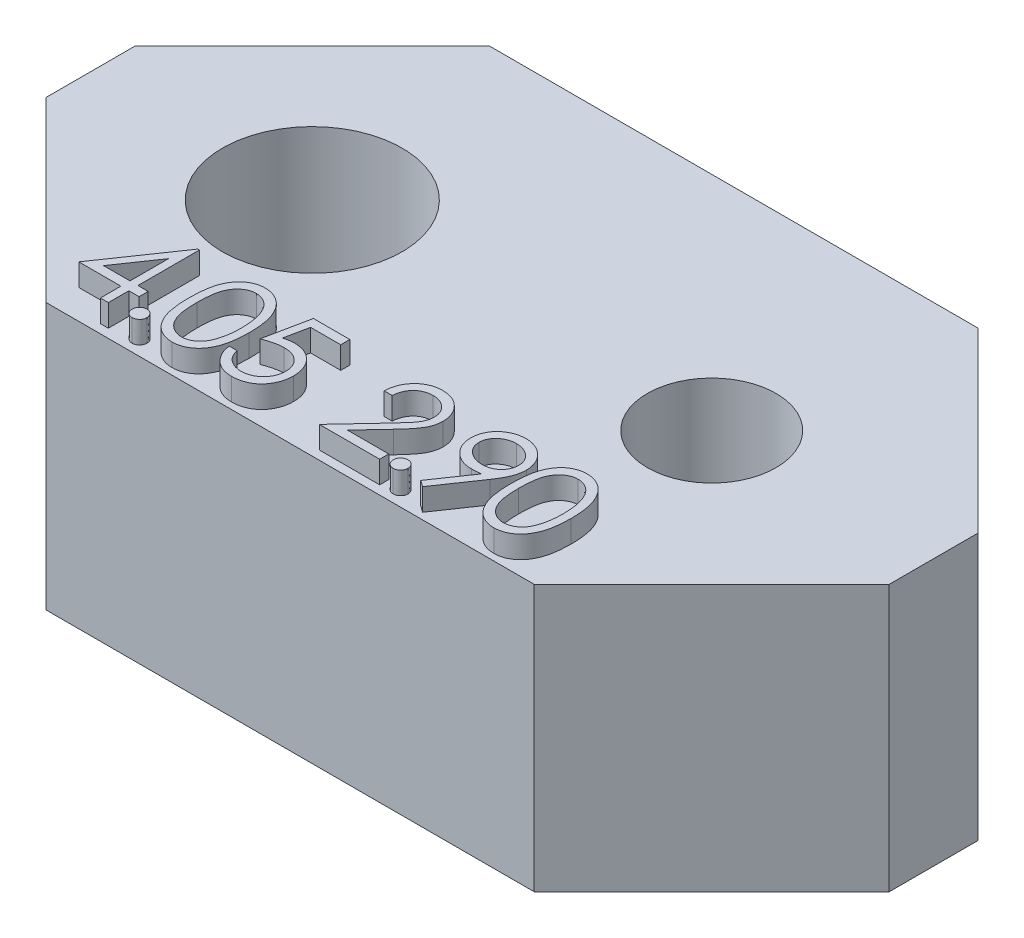
from build123d import *

# Parameters (mm, degrees)
SKETCH_1_R      = 2.025
SKETCH_1_R_2    = 1.45
EXTRUDE_1_DEPTH = 6
SKETCH_1_3_R    = 2.025
SKETCH_1_3_R_2  = 1.45
EXTRUDE_2_DEPTH = 2
EXTRUDE_3_DEPTH = 0.5


with BuildPart() as part:
    # Эскиз1 → Бобышка-Вытянуть1 (new body)
    with BuildSketch(Plane(origin=(0, 0, 0), x_dir=(1, 0, 0), z_dir=(0, 1, 0))):
        Polygon((9.5, 1), (5.5, 5), (-5.5, 5), (-9.5, 1), (-9.5, -1), (-5.5, -5), (5.5, -5), (9.5, -1), align=None)
        with Locations((-4.5, 0)):
            Circle(SKETCH_1_R, mode=Mode.SUBTRACT)
        with Locations((4.5, 0)):
            Circle(SKETCH_1_R_2, mode=Mode.SUBTRACT)
    extrude(amount=EXTRUDE_1_DEPTH)

    # Эскиз1<3> → Бобышка-Вытянуть2 (add)
    with BuildSketch(Plane(origin=(0, 0, 0), x_dir=(1, 0, 0), z_dir=(0, 1, 0))):
        with Locations((-4.5, 0)):
            Circle(SKETCH_1_3_R)
        with Locations((4.5, 0)):
            Circle(SKETCH_1_3_R_2)
    extrude(amount=EXTRUDE_2_DEPTH)

    # Эскиз3 → Бобышка-Вытянуть3 (add)
    # profile 1 of 8: a face of its own
    with BuildSketch(Plane(origin=(0, 6, 0), x_dir=(1, 0, 0), z_dir=(0, 1, 0))):
        Polygon((-4.331330128, -2.748717949), (-4.294871795, -2.748717949), (-4.294871795, -4.133333333), (-4.064102564, -4.133333333), (-4.064102564, -4.338461538), (-4.294871795, -4.338461538), (-4.294871795, -4.8), (-4.474358974, -4.8), (-4.474358974, -4.338461538), (-5.423076923, -4.338461538), align=None)
        Polygon((-4.474358974, -4.133333333), (-4.474358974, -3.26474359), (-5.070512821, -4.133333333), align=None, mode=Mode.SUBTRACT)
    # profile 2 of 8: a face of its own
    with BuildSketch(Plane(origin=(0, 6, 0), x_dir=(1, 0, 0), z_dir=(0, 1, 0))):
        with BuildLine():
            add(Edge.make_bspline(
                [(-3.733333333, -4.492307692), (-3.722196069, -4.492969502), (-3.700362765, -4.494266902), (-3.668797549, -4.503167858), (-3.640229172, -4.518972807), (-3.614782175, -4.540037252), (-3.593807045, -4.565577631), (-3.577438844, -4.59391815), (-3.568615424, -4.625747632), (-3.567327474, -4.647707446), (-3.566666667, -4.658974359)],
                knots=[0, 0, 0, 0, 1.020151414, 1.999887582, 2.974338812, 3.990962822, 5.007586832, 5.987933904, 6.967670073, 8, 8, 8, 8], degree=3))
            add(Edge.make_bspline(
                [(-3.566666667, -4.658974359), (-3.567349867, -4.669970547), (-3.568697128, -4.69165487), (-3.577418619, -4.723244277), (-3.59393179, -4.751602508), (-3.6146375, -4.777489444), (-3.640235462, -4.798598513), (-3.668865089, -4.814268996), (-3.700288665, -4.82380727), (-3.722183707, -4.825022297), (-3.733333333, -4.825641026)],
                knots=[0, 0, 0, 0, 1.009421747, 1.99056486, 2.972319754, 3.999869655, 5.017953583, 5.993804169, 6.978383603, 8, 8, 8, 8], degree=3))
            add(Edge.make_bspline(
                [(-3.733333333, -4.825641026), (-3.744490994, -4.825044684), (-3.766273669, -4.82388047), (-3.797579952, -4.814073152), (-3.826383934, -4.798745461), (-3.851976912, -4.777450084), (-3.872856039, -4.751735716), (-3.888641972, -4.723048975), (-3.898122057, -4.691745297), (-3.899368841, -4.669988358), (-3.9, -4.658974359)],
                knots=[0, 0, 0, 0, 1.022052826, 1.995314843, 2.982371812, 4.00089066, 5.028879526, 6.005146991, 6.990147033, 8, 8, 8, 8], degree=3))
            add(Edge.make_bspline(
                [(-3.9, -4.658974359), (-3.899393086, -4.647688999), (-3.898208161, -4.625655719), (-3.88862207, -4.594113372), (-3.87297852, -4.565445692), (-3.85183258, -4.540076218), (-3.826390125, -4.518826331), (-3.797649437, -4.503360735), (-3.766198271, -4.494194785), (-3.744478306, -4.492947633), (-3.733333333, -4.492307692)],
                knots=[0, 0, 0, 0, 1.032775665, 2.016367738, 2.991239715, 4.008302682, 5.025365648, 6.011011707, 6.979408107, 8, 8, 8, 8], degree=3))
        make_face()
    # profile 3 of 8: a face of its own
    with BuildSketch(Plane(origin=(0, 6, 0), x_dir=(1, 0, 0), z_dir=(0, 1, 0))):
        with BuildLine():
            add(Edge.make_bspline(
                [(-3.479487179, -3.800801282), (-3.479299741, -3.768745632), (-3.478935638, -3.706477069), (-3.474885111, -3.615742988), (-3.468156344, -3.530622823), (-3.458934988, -3.4511125), (-3.447713285, -3.377191491), (-3.432733007, -3.309057344), (-3.41569712, -3.246394712), (-3.395952865, -3.188999256), (-3.373674129, -3.136097711), (-3.34942598, -3.086711882), (-3.322246097, -3.040916492), (-3.293687861, -2.997980612), (-3.262595249, -2.958607072), (-3.229853083, -2.922239836), (-3.19418344, -2.889719407), (-3.156798863, -2.860092949), (-3.117360884, -2.834121822), (-3.076993646, -2.811245972), (-3.0354193, -2.79170319), (-2.992524338, -2.776337227), (-2.948694305, -2.763645314), (-2.903775981, -2.754965916), (-2.857695202, -2.749504825), (-2.826591525, -2.748982729), (-2.810817308, -2.748717949)],
                knots=[0, 0, 0, 0, 1.646270934, 3.197905019, 4.663502075, 6.030701355, 7.308322542, 8.50163776, 9.611534131, 10.641858119, 11.616356847, 12.558055219, 13.465016945, 14.349605745, 15.204443733, 16.039544428, 16.859896111, 17.680448484, 18.487036065, 19.28249412, 20.06191084, 20.843045899, 21.620316918, 22.403196591, 23.190181807, 24, 24, 24, 24], degree=3))
            add(Edge.make_bspline(
                [(-2.810817308, -2.748717949), (-2.79491132, -2.7489967), (-2.763279315, -2.749551049), (-2.716513386, -2.754879016), (-2.670827854, -2.763719658), (-2.626417489, -2.776245929), (-2.582917497, -2.791786316), (-2.540668121, -2.811264669), (-2.499406931, -2.833938307), (-2.459789624, -2.860580523), (-2.421381272, -2.890284681), (-2.385125294, -2.923863349), (-2.351018387, -2.960977474), (-2.318632499, -3.001229968), (-2.288886443, -3.045392873), (-2.260558767, -3.092698079), (-2.235203318, -3.143972859), (-2.210783504, -3.198361697), (-2.189705226, -3.257369502), (-2.170695943, -3.320663651), (-2.155336532, -3.388991758), (-2.142542662, -3.461995327), (-2.132631293, -3.53994246), (-2.125412641, -3.622666069), (-2.121599449, -3.710220578), (-2.120881334, -3.770082206), (-2.120512821, -3.800801282)],
                knots=[0, 0, 0, 0, 0.810914788, 1.612654377, 2.396697861, 3.181598691, 3.963628158, 4.749916497, 5.551656086, 6.361998678, 7.18212741, 8.025565596, 8.878627764, 9.750805457, 10.657531673, 11.591944965, 12.560506719, 13.57287815, 14.630710178, 15.753379473, 16.941251878, 18.199788006, 19.531962791, 20.947069417, 22.433333509, 24, 24, 24, 24], degree=3))
            add(Edge.make_bspline(
                [(-2.120512821, -3.800801282), (-2.120885155, -3.831386372), (-2.121610632, -3.890980173), (-2.125369893, -3.978140731), (-2.132774825, -4.060425327), (-2.142037676, -4.138031305), (-2.154866797, -4.210635659), (-2.170641178, -4.27848963), (-2.188155648, -4.341886242), (-2.209775531, -4.400306134), (-2.233438794, -4.454564262), (-2.25918462, -4.505231204), (-2.286767378, -4.552754799), (-2.316818089, -4.596754655), (-2.348848611, -4.637542459), (-2.38354449, -4.674398243), (-2.419927682, -4.708210056), (-2.458449062, -4.7382967), (-2.498684235, -4.764630874), (-2.539803707, -4.788181646), (-2.582537069, -4.807171757), (-2.625915899, -4.823477495), (-2.67056068, -4.835934896), (-2.71641576, -4.844548528), (-2.763247895, -4.850589584), (-2.794905932, -4.85105043), (-2.810817308, -4.851282051)],
                knots=[0, 0, 0, 0, 1.561518951, 3.042555995, 4.452378317, 5.7783523, 7.031515105, 8.214008947, 9.334062868, 10.386615937, 11.391082383, 12.354592575, 13.286541444, 14.194233754, 15.072674879, 15.931287219, 16.775624067, 17.606195743, 18.42308326, 19.229000347, 20.022332153, 20.807536673, 21.593273796, 22.3848459, 23.188221202, 24, 24, 24, 24], degree=3))
            add(Edge.make_bspline(
                [(-2.810817308, -4.851282051), (-2.826591087, -4.851015562), (-2.857693901, -4.850490098), (-2.903781002, -4.84505368), (-2.948513826, -4.836313393), (-2.992113114, -4.824075333), (-3.034802552, -4.809095427), (-3.07600043, -4.789579036), (-3.11616482, -4.767102426), (-3.155188567, -4.741505042), (-3.192338373, -4.712178366), (-3.22782329, -4.679741629), (-3.260751873, -4.643385394), (-3.291399927, -4.603683724), (-3.320527978, -4.561001871), (-3.347321905, -4.514757087), (-3.37210525, -4.465132738), (-3.394758674, -4.411808217), (-3.414843624, -4.354005401), (-3.432585172, -4.291063014), (-3.446593262, -4.222425507), (-3.458583522, -4.148644155), (-3.468254598, -4.069401909), (-3.47485707, -3.98465575), (-3.478937821, -3.894458488), (-3.479300718, -3.832590045), (-3.479487179, -3.800801282)],
                knots=[0, 0, 0, 0, 0.810891512, 1.598919785, 2.382837074, 3.152667961, 3.926044502, 4.706494248, 5.493654104, 6.291793342, 7.103789334, 7.925228297, 8.761435821, 9.622817696, 10.50288917, 11.416980706, 12.369136599, 13.353924996, 14.394355917, 15.514179734, 16.714354668, 17.994756427, 19.357759367, 20.818452758, 22.365282078, 24, 24, 24, 24], degree=3))
        make_face()
        with BuildLine():
            add(Edge.make_bspline(
                [(-3.3, -3.8), (-3.299931745, -3.826713542), (-3.299799274, -3.878559282), (-3.296338588, -3.953898288), (-3.29162417, -4.024167048), (-3.285543428, -4.089454783), (-3.276513172, -4.149540504), (-3.266395008, -4.204837466), (-3.254081814, -4.25505303), (-3.239513232, -4.300531779), (-3.222919462, -4.342045532), (-3.204801826, -4.380674798), (-3.185338556, -4.416875905), (-3.163556184, -4.450323681), (-3.139833291, -4.481127203), (-3.114705714, -4.509831679), (-3.087235666, -4.535429954), (-3.049233527, -4.566131014), (-2.999064113, -4.597856233), (-2.935852425, -4.62548257), (-2.870899024, -4.642843974), (-2.826812596, -4.645051835), (-2.804807692, -4.646153846)],
                knots=[0, 0, 0, 0, 1.459021318, 2.831673884, 4.118529203, 5.306027144, 6.411944654, 7.436330062, 8.375795394, 9.233974572, 10.042671642, 10.816086306, 11.563610507, 12.285937304, 12.993564865, 13.685989202, 14.367179055, 15.041617293, 16.353048772, 17.594441528, 18.799311195, 20, 20, 20, 20], degree=3))
            add(Edge.make_bspline(
                [(-2.804807692, -4.646153846), (-2.782660451, -4.645240829), (-2.738411695, -4.643416678), (-2.673763812, -4.6258174), (-2.611003658, -4.599263377), (-2.561819692, -4.567864803), (-2.524401096, -4.5379629), (-2.497591387, -4.512468816), (-2.472984502, -4.483922606), (-2.449646174, -4.453123008), (-2.428240988, -4.419481588), (-2.408776338, -4.383160117), (-2.391014425, -4.344057729), (-2.38089497, -4.316760736), (-2.375721154, -4.302804487)],
                knots=[0, 0, 0, 0, 1.353760809, 2.704726607, 4.075137775, 5.516104923, 6.260822281, 7.007110065, 7.778089737, 8.566572457, 9.372053459, 10.217411131, 11.088608312, 12, 12, 12, 12], degree=3))
            add(Edge.make_bspline(
                [(-2.375721154, -4.302804487), (-2.369691572, -4.284958922), (-2.357448936, -4.248724771), (-2.341670779, -4.19251697), (-2.329244837, -4.133543962), (-2.318065771, -4.072158181), (-2.310435453, -4.007906923), (-2.304293845, -3.940988989), (-2.30067631, -3.871353925), (-2.300227881, -3.824042502), (-2.3, -3.8)],
                knots=[0, 0, 0, 0, 0.884706709, 1.796334032, 2.740027952, 3.714592787, 4.726048262, 5.777819803, 6.87074269, 8, 8, 8, 8], degree=3))
            add(Edge.make_bspline(
                [(-2.3, -3.8), (-2.300314394, -3.775961387), (-2.300929415, -3.728936722), (-2.303280266, -3.66006919), (-2.30935088, -3.594659041), (-2.316093233, -3.532424485), (-2.326034502, -3.473710026), (-2.336753249, -3.418024137), (-2.351153942, -3.366056695), (-2.36653667, -3.316994077), (-2.384142611, -3.271393703), (-2.40352303, -3.229042967), (-2.424221178, -3.18973741), (-2.446702458, -3.153584872), (-2.470699992, -3.120423419), (-2.496847163, -3.090917937), (-2.524106804, -3.064153955), (-2.562288053, -3.033603915), (-2.612273362, -3.002454375), (-2.674470874, -2.973788227), (-2.739196957, -2.957326345), (-2.782953216, -2.955005381), (-2.804807692, -2.953846154)],
                knots=[0, 0, 0, 0, 1.31362396, 2.569729283, 3.763502607, 4.902122613, 5.988968491, 7.01645872, 7.998833611, 8.933434873, 9.825090667, 10.667526885, 11.477055099, 12.250526234, 12.991942729, 13.710640831, 14.402115721, 15.076753259, 16.378508321, 17.609869233, 18.806226677, 20, 20, 20, 20], degree=3))
            add(Edge.make_bspline(
                [(-2.804807692, -2.953846154), (-2.826928031, -2.955006981), (-2.871209005, -2.957330749), (-2.936607837, -2.973726893), (-2.999296037, -3.002305731), (-3.049149166, -3.033707087), (-3.087357044, -3.063614693), (-3.11426144, -3.08954981), (-3.139487824, -3.117919098), (-3.16272651, -3.149005907), (-3.184491815, -3.182414688), (-3.204480965, -3.218408268), (-3.222490867, -3.257169047), (-3.239110602, -3.298664153), (-3.253723624, -3.344138979), (-3.265777317, -3.394292689), (-3.276912776, -3.44941377), (-3.284795787, -3.509824918), (-3.291803648, -3.575129005), (-3.296307275, -3.645573187), (-3.299810851, -3.721038548), (-3.299935687, -3.773152352), (-3.3, -3.8)],
                knots=[0, 0, 0, 0, 1.207732386, 2.417664972, 3.655092373, 4.956220595, 5.625982001, 6.301752483, 6.994047911, 7.697131622, 8.419323945, 9.170223765, 9.943494443, 10.752040957, 11.610060368, 12.549350801, 13.567764191, 14.679664412, 15.874934091, 17.154273443, 18.533957287, 20, 20, 20, 20], degree=3))
        make_face(mode=Mode.SUBTRACT)
    # profile 4 of 8: a face of its own
    with BuildSketch(Plane(origin=(0, 6, 0), x_dir=(1, 0, 0), z_dir=(0, 1, 0))):
        with BuildLine():
            Line((-0.853846154, -2.8), (-0.853846154, -3.005128205))
            Line((-0.853846154, -3.005128205), (-1.534134615, -3.005128205))
            Line((-1.534134615, -3.005128205), (-1.641907051, -3.531169872))
            add(Edge.make_bspline(
                [(-1.641907051, -3.531169872), (-1.620732266, -3.525324002), (-1.579709468, -3.513998554), (-1.519160976, -3.501423828), (-1.461679717, -3.493843575), (-1.424379506, -3.49280854), (-1.406330128, -3.492307692)],
                knots=[0, 0, 0, 0, 1.100273476, 2.13160584, 3.095893838, 4, 4, 4, 4], degree=3))
            add(Edge.make_bspline(
                [(-1.406330128, -3.492307692), (-1.383996563, -3.492791084), (-1.340083193, -3.493741553), (-1.275832366, -3.502868324), (-1.214499284, -3.51723399), (-1.156212215, -3.537302859), (-1.100863329, -3.562965564), (-1.048961866, -3.595022673), (-0.999728772, -3.632470291), (-0.95404729, -3.675524583), (-0.912604828, -3.722908364), (-0.87616712, -3.773855719), (-0.845217068, -3.827871526), (-0.820325208, -3.885471874), (-0.800448446, -3.946019962), (-0.787218735, -4.010152866), (-0.778409187, -4.077266077), (-0.777424966, -4.123154403), (-0.776923077, -4.146554487)],
                knots=[0, 0, 0, 0, 1.052922333, 2.070308379, 3.05430497, 4.020497103, 4.973039431, 5.925935799, 6.892292201, 7.88610001, 8.88166317, 9.857072816, 10.836096531, 11.812156883, 12.81219415, 13.836441305, 14.89672472, 16, 16, 16, 16], degree=3))
            add(Edge.make_bspline(
                [(-0.776923077, -4.146554487), (-0.77730312, -4.162852899), (-0.77805807, -4.195229463), (-0.781897263, -4.243311864), (-0.789289101, -4.29037634), (-0.799213514, -4.336429135), (-0.812094896, -4.381383062), (-0.827688641, -4.425366792), (-0.846772086, -4.468106567), (-0.8677043, -4.510006793), (-0.891273716, -4.550120226), (-0.917432863, -4.587633932), (-0.945070287, -4.623110665), (-0.974808221, -4.656169941), (-1.006923076, -4.686594522), (-1.041025914, -4.714564969), (-1.07684461, -4.740554301), (-1.11493332, -4.763507555), (-1.15444331, -4.784629244), (-1.195945149, -4.80195698), (-1.238494121, -4.81744871), (-1.282702621, -4.829797012), (-1.328470514, -4.839472757), (-1.375873243, -4.846044529), (-1.424662197, -4.850831064), (-1.457733633, -4.851130697), (-1.474439103, -4.851282051)],
                knots=[0, 0, 0, 0, 1.056347294, 2.098418968, 3.122841568, 4.141288669, 5.149314143, 6.15115421, 7.162517403, 8.180376062, 9.185164535, 10.17417709, 11.141909838, 12.097768115, 13.052685741, 14.0056014, 14.954263652, 15.917497458, 16.885230207, 17.854509472, 18.828990115, 19.81800267, 20.826176721, 21.857883937, 22.917946725, 24, 24, 24, 24], degree=3))
            add(Edge.make_bspline(
                [(-1.474439103, -4.851282051), (-1.494367206, -4.850887287), (-1.533573395, -4.850110634), (-1.591013719, -4.841985785), (-1.646279208, -4.830349262), (-1.69892498, -4.812842822), (-1.749422845, -4.790907225), (-1.797092969, -4.763183698), (-1.843153413, -4.731767068), (-1.885731719, -4.69469258), (-1.925249499, -4.654169333), (-1.960624647, -4.610193538), (-1.992129548, -4.563491), (-2.019259689, -4.513834912), (-2.042401415, -4.461355751), (-2.060581408, -4.405856894), (-2.075254754, -4.34762832), (-2.081462423, -4.3075406), (-2.084615385, -4.287179487)],
                knots=[0, 0, 0, 0, 1.0467383, 2.05933395, 3.04377827, 4.011590433, 4.970194871, 5.932262533, 6.905835911, 7.896367577, 8.894135286, 9.877477877, 10.858688626, 11.851381753, 12.8477658, 13.868841284, 14.917554742, 16, 16, 16, 16], degree=3))
            Line((-2.084615385, -4.287179487), (-1.905128205, -4.287179487))
            add(Edge.make_bspline(
                [(-1.905128205, -4.287179487), (-1.900711887, -4.306251746), (-1.892223477, -4.342909686), (-1.873591621, -4.394413309), (-1.850811121, -4.440310009), (-1.823722921, -4.481206913), (-1.791408618, -4.516869197), (-1.754534659, -4.548650376), (-1.713193103, -4.577321878), (-1.667254114, -4.601220602), (-1.618789498, -4.621602747), (-1.568065378, -4.635175144), (-1.516462894, -4.644718511), (-1.481560968, -4.645673803), (-1.464022436, -4.646153846)],
                knots=[0, 0, 0, 0, 1.136247022, 2.183929868, 3.172523383, 4.106158343, 5.02341133, 5.958108904, 6.928429099, 7.938127109, 8.96079061, 9.975095812, 10.982467395, 12, 12, 12, 12], degree=3))
            add(Edge.make_bspline(
                [(-1.464022436, -4.646153846), (-1.446903325, -4.64568483), (-1.413195655, -4.644761334), (-1.363589148, -4.637653327), (-1.315696077, -4.626706143), (-1.269989016, -4.610323369), (-1.225668137, -4.590412102), (-1.183854553, -4.56486063), (-1.143338624, -4.535454905), (-1.10537969, -4.501765402), (-1.070614291, -4.464639862), (-1.039896507, -4.424938494), (-1.014309699, -4.382586011), (-0.992747352, -4.338315638), (-0.976374038, -4.291642176), (-0.964693477, -4.242784362), (-0.957834586, -4.191621516), (-0.956891055, -4.156724768), (-0.956410256, -4.138942308)],
                knots=[0, 0, 0, 0, 1.027316725, 2.022795036, 3.002884548, 3.971462791, 4.93288096, 5.914575861, 6.907176829, 7.935150275, 8.956128384, 9.956726525, 10.942570165, 11.921478529, 12.907843606, 13.90538589, 14.932640048, 16, 16, 16, 16], degree=3))
            add(Edge.make_bspline(
                [(-0.956410256, -4.138942308), (-0.95678653, -4.122899021), (-0.957523033, -4.09149657), (-0.963540502, -4.045554166), (-0.974007343, -4.002083857), (-0.988535275, -3.960875723), (-1.006980708, -3.921890899), (-1.029521458, -3.88508915), (-1.056580542, -3.850955531), (-1.087490193, -3.819474072), (-1.12135193, -3.790419858), (-1.158748355, -3.765651808), (-1.198896884, -3.744815284), (-1.241313798, -3.72683357), (-1.287008026, -3.713918859), (-1.335074673, -3.704222924), (-1.386032792, -3.698614146), (-1.420873185, -3.697835924), (-1.438782051, -3.697435897)],
                knots=[0, 0, 0, 0, 1.045622112, 2.046656509, 3.013763289, 3.955457236, 4.890082067, 5.820317437, 6.762574623, 7.722996705, 8.69280354, 9.665887285, 10.63943826, 11.638615906, 12.663482002, 13.728887084, 14.832589034, 16, 16, 16, 16], degree=3))
            add(Edge.make_bspline(
                [(-1.438782051, -3.697435897), (-1.454284296, -3.697767664), (-1.486292499, -3.698452677), (-1.535391257, -3.70349639), (-1.586986528, -3.711633129), (-1.640880525, -3.722825271), (-1.697235101, -3.7374716), (-1.75593133, -3.755022744), (-1.817092625, -3.776006743), (-1.858302754, -3.791853722), (-1.879487179, -3.8)],
                knots=[0, 0, 0, 0, 0.817624296, 1.688186739, 2.600797293, 3.572016777, 4.590301741, 5.671205678, 6.80286297, 8, 8, 8, 8], degree=3))
            Line((-1.879487179, -3.8), (-1.674358974, -2.8))
            Line((-1.674358974, -2.8), (-0.853846154, -2.8))
        make_face()
    # profile 5 of 8: a face of its own
    with BuildSketch(Plane(origin=(0, 6, 0), x_dir=(1, 0, 0), z_dir=(0, 1, 0))):
        with BuildLine():
            Line((0.715384615, -3.415384615), (0.535897436, -3.415384615))
            add(Edge.make_bspline(
                [(0.535897436, -3.415384615), (0.537067238, -3.39157268), (0.539364697, -3.344806671), (0.550123719, -3.276621582), (0.565518506, -3.211447411), (0.587285052, -3.14980746), (0.61431721, -3.091156713), (0.646734369, -3.035728133), (0.685130855, -2.983733168), (0.72867756, -2.935653829), (0.775973925, -2.891546646), (0.827005891, -2.853457935), (0.88063162, -2.821276409), (0.93668842, -2.794372842), (0.995808742, -2.774178644), (1.057456089, -2.75919485), (1.12190131, -2.750179796), (1.165809894, -2.749210775), (1.188141026, -2.748717949)],
                knots=[0, 0, 0, 0, 1.10065271, 2.161652631, 3.183658789, 4.190468796, 5.17591951, 6.163126047, 7.15150782, 8.156236427, 9.156009102, 10.134482811, 11.092018607, 12.041330605, 13.001268258, 13.972401359, 14.968799086, 16, 16, 16, 16], degree=3))
            add(Edge.make_bspline(
                [(1.188141026, -2.748717949), (1.210071354, -2.749231352), (1.253163665, -2.750240172), (1.316056245, -2.758903618), (1.375928984, -2.772472527), (1.432664851, -2.791509908), (1.485811173, -2.817101009), (1.535767199, -2.84784246), (1.583127662, -2.883396649), (1.62576011, -2.925255971), (1.664907584, -2.969943048), (1.698680301, -3.017650422), (1.727602109, -3.066924299), (1.751709354, -3.118140414), (1.76945572, -3.171781002), (1.782928981, -3.227065118), (1.790544646, -3.28456501), (1.79171346, -3.323483042), (1.792307692, -3.343269231)],
                knots=[0, 0, 0, 0, 1.111607364, 2.184268762, 3.212621178, 4.221274766, 5.211760367, 6.196651075, 7.1921475, 8.207485113, 9.220403448, 10.201281604, 11.166441695, 12.114753415, 13.065576456, 14.026450734, 14.996634279, 16, 16, 16, 16], degree=3))
            add(Edge.make_bspline(
                [(1.792307692, -3.343269231), (1.791340114, -3.371125136), (1.789421936, -3.426348115), (1.77301372, -3.507499466), (1.747387143, -3.586124277), (1.71653151, -3.649402735), (1.685404399, -3.700393303), (1.657354395, -3.74237542), (1.62451736, -3.787578545), (1.586415361, -3.835851309), (1.543836577, -3.887571826), (1.496395341, -3.942708852), (1.443753351, -4.00069272), (1.406805637, -4.040295921), (1.387660256, -4.060817308)],
                knots=[0, 0, 0, 0, 1.184426356, 2.348067706, 3.509069118, 4.696110526, 5.333549288, 6.050745305, 6.844228056, 7.710549037, 8.667450064, 9.695053472, 10.805634456, 12, 12, 12, 12], degree=3))
            Line((1.387660256, -4.060817308), (0.887259615, -4.594871795))
            Line((0.887259615, -4.594871795), (1.817948718, -4.594871795))
            Line((1.817948718, -4.594871795), (1.817948718, -4.8))
            Line((1.817948718, -4.8), (0.458974359, -4.8))
            Line((0.458974359, -4.8), (1.234615385, -3.972275641))
            add(Edge.make_bspline(
                [(1.234615385, -3.972275641), (1.253499891, -3.952562323), (1.289773164, -3.914697074), (1.341077494, -3.859415382), (1.387156916, -3.80812993), (1.428309711, -3.760937617), (1.463643143, -3.717148149), (1.494998704, -3.678179747), (1.520121899, -3.642320061), (1.547387839, -3.600753996), (1.573795829, -3.550004101), (1.596488604, -3.48798485), (1.61032566, -3.424140705), (1.611985566, -3.380996684), (1.612820513, -3.359294872)],
                knots=[0, 0, 0, 0, 1.329631726, 2.553950428, 3.673215718, 4.687767853, 5.603093632, 6.413772471, 7.123043292, 7.734684054, 8.834405432, 9.900288307, 10.943827018, 12, 12, 12, 12], degree=3))
            add(Edge.make_bspline(
                [(1.612820513, -3.359294872), (1.612457232, -3.345648358), (1.611741274, -3.318753701), (1.60542259, -3.279321839), (1.595873729, -3.241284802), (1.582190724, -3.204525591), (1.56412973, -3.16941379), (1.542144941, -3.135906659), (1.516779191, -3.103512964), (1.487435608, -3.073139651), (1.455200454, -3.045321819), (1.421146597, -3.020679485), (1.385117966, -3.000085707), (1.347266468, -2.983203709), (1.307697628, -2.969960634), (1.266334917, -2.960784303), (1.223292622, -2.955022883), (1.193902053, -2.954243357), (1.178926282, -2.953846154)],
                knots=[0, 0, 0, 0, 0.991446411, 1.95395049, 2.89581595, 3.838931463, 4.798493298, 5.75982156, 6.748411868, 7.785213223, 8.824556874, 9.840280684, 10.836137867, 11.835679398, 12.848801643, 13.863922112, 14.911575587, 16, 16, 16, 16], degree=3))
            add(Edge.make_bspline(
                [(1.178926282, -2.953846154), (1.163285806, -2.954254744), (1.132570494, -2.955057147), (1.087473904, -2.960670098), (1.04445346, -2.970353435), (1.003400944, -2.983597249), (0.964246895, -3.000430705), (0.927181726, -3.021397417), (0.892288647, -3.046416556), (0.859502062, -3.074782588), (0.829294074, -3.106364074), (0.802753002, -3.141569767), (0.779562137, -3.179756862), (0.759328289, -3.220822319), (0.742896466, -3.265138765), (0.73034038, -3.312548882), (0.720405039, -3.362846814), (0.717085885, -3.397581149), (0.715384615, -3.415384615)],
                knots=[0, 0, 0, 0, 1.031018746, 2.02475058, 2.990194455, 3.934040569, 4.864654155, 5.795059489, 6.735614925, 7.690564532, 8.649604399, 9.611025574, 10.590972636, 11.591080095, 12.624614302, 13.701020113, 14.821632451, 16, 16, 16, 16], degree=3))
        make_face()
    # profile 6 of 8: a face of its own
    with BuildSketch(Plane(origin=(0, 6, 0), x_dir=(1, 0, 0), z_dir=(0, 1, 0))):
        with BuildLine():
            add(Edge.make_bspline(
                [(2.148717949, -4.492307692), (2.159855213, -4.492969502), (2.181688517, -4.494266902), (2.213253733, -4.503167858), (2.24182211, -4.518972807), (2.267269107, -4.540037252), (2.288244237, -4.565577631), (2.304612438, -4.59391815), (2.313435858, -4.625747632), (2.314723808, -4.647707446), (2.315384615, -4.658974359)],
                knots=[0, 0, 0, 0, 1.020151414, 1.999887582, 2.974338812, 3.990962822, 5.007586832, 5.987933904, 6.967670073, 8, 8, 8, 8], degree=3))
            add(Edge.make_bspline(
                [(2.315384615, -4.658974359), (2.314701415, -4.669970547), (2.313354154, -4.69165487), (2.304632663, -4.723244277), (2.288119492, -4.751602508), (2.267413782, -4.777489444), (2.24181582, -4.798598513), (2.213186193, -4.814268996), (2.181762617, -4.82380727), (2.159867575, -4.825022297), (2.148717949, -4.825641026)],
                knots=[0, 0, 0, 0, 1.009421747, 1.99056486, 2.972319754, 3.999869655, 5.017953583, 5.993804169, 6.978383603, 8, 8, 8, 8], degree=3))
            add(Edge.make_bspline(
                [(2.148717949, -4.825641026), (2.137560288, -4.825044684), (2.115777613, -4.82388047), (2.08447133, -4.814073152), (2.055667348, -4.798745461), (2.03007437, -4.777450084), (2.009195243, -4.751735716), (1.99340931, -4.723048975), (1.983929225, -4.691745297), (1.982682441, -4.669988358), (1.982051282, -4.658974359)],
                knots=[0, 0, 0, 0, 1.022052826, 1.995314843, 2.982371812, 4.00089066, 5.028879526, 6.005146991, 6.990147033, 8, 8, 8, 8], degree=3))
            add(Edge.make_bspline(
                [(1.982051282, -4.658974359), (1.982658196, -4.647688999), (1.983843121, -4.625655719), (1.993429212, -4.594113372), (2.009072762, -4.565445692), (2.030218702, -4.540076218), (2.055661157, -4.518826331), (2.084401845, -4.503360735), (2.115853011, -4.494194785), (2.137572976, -4.492947633), (2.148717949, -4.492307692)],
                knots=[0, 0, 0, 0, 1.032775665, 2.016367738, 2.991239715, 4.008302682, 5.025365648, 6.011011707, 6.979408107, 8, 8, 8, 8], degree=3))
        make_face()
    # profile 7 of 8: a face of its own
    with BuildSketch(Plane(origin=(0, 6, 0), x_dir=(1, 0, 0), z_dir=(0, 1, 0))):
        with BuildLine():
            Line((2.838461538, -4.851282051), (2.695032051, -4.751522436))
            Line((2.695032051, -4.751522436), (3.251121795, -3.938621795))
            add(Edge.make_bspline(
                [(3.251121795, -3.938621795), (3.215641375, -3.942960688), (3.145778449, -3.951504211), (3.07541439, -3.953073728), (3.040785256, -3.953846154)],
                knots=[0, 0, 0, 0, 1.015715272, 2, 2, 2, 2], degree=3))
            add(Edge.make_bspline(
                [(3.040785256, -3.953846154), (3.019789801, -3.953308396), (2.978577557, -3.952252824), (2.917988041, -3.943886076), (2.859767721, -3.931000289), (2.804070946, -3.911772429), (2.750688372, -3.88787631), (2.699736535, -3.85824373), (2.651284026, -3.823382992), (2.605851221, -3.783478426), (2.564530227, -3.739662396), (2.527716914, -3.693287743), (2.497121982, -3.643815759), (2.47170679, -3.592255634), (2.452432245, -3.537866291), (2.438396509, -3.481266633), (2.429755164, -3.422059981), (2.428727109, -3.381759906), (2.428205128, -3.361298077)],
                knots=[0, 0, 0, 0, 1.060718605, 2.082097864, 3.085795603, 4.069760067, 5.054557537, 6.03741023, 7.043284206, 8.066802108, 9.088538119, 10.083643548, 11.053783639, 12.022749082, 12.983451788, 13.964007469, 14.966251758, 16, 16, 16, 16], degree=3))
            add(Edge.make_bspline(
                [(2.428205128, -3.361298077), (2.429196234, -3.33331599), (2.431141573, -3.278392829), (2.446797869, -3.198144961), (2.472546634, -3.122266936), (2.508448563, -3.050958254), (2.553668404, -2.985244688), (2.60801617, -2.926039769), (2.671161293, -2.874185567), (2.741665303, -2.829611808), (2.81786703, -2.793763238), (2.897677691, -2.767340781), (2.98048576, -2.751798639), (3.036581571, -2.749749576), (3.064823718, -2.748717949)],
                knots=[0, 0, 0, 0, 1.022988612, 2.007919123, 2.978103895, 3.94594894, 4.918897164, 5.887013414, 6.875921846, 7.89917871, 8.930658928, 9.948724884, 10.967259574, 12, 12, 12, 12], degree=3))
            add(Edge.make_bspline(
                [(3.064823718, -2.748717949), (3.092531386, -2.749763756), (3.147279127, -2.751830173), (3.227787131, -2.76696387), (3.304896284, -2.79247054), (3.378179133, -2.827718862), (3.446030226, -2.871902238), (3.507044975, -2.924550537), (3.559830997, -2.985696553), (3.604301786, -3.053861404), (3.639998952, -3.127099679), (3.665754543, -3.203547635), (3.681609193, -3.282655476), (3.683607095, -3.336252318), (3.684615385, -3.363301282)],
                knots=[0, 0, 0, 0, 1.026385292, 2.028040595, 3.023318987, 4.028184125, 5.03290303, 6.015178782, 7.004435299, 8.016004309, 9.023023918, 10.015172535, 10.998308025, 12, 12, 12, 12], degree=3))
            add(Edge.make_bspline(
                [(3.684615385, -3.363301282), (3.683942008, -3.38429772), (3.682576232, -3.426883744), (3.673012628, -3.491586797), (3.656772522, -3.557558928), (3.63834298, -3.61339984), (3.62055317, -3.659518954), (3.603809666, -3.695948428), (3.585231293, -3.734292007), (3.563563427, -3.774147629), (3.540270686, -3.816023363), (3.513951099, -3.859499201), (3.485205058, -3.904633482), (3.464730933, -3.93506039), (3.454246795, -3.950641026)],
                knots=[0, 0, 0, 0, 1.179839688, 2.393009684, 3.667231171, 4.993948276, 5.694988576, 6.444077775, 7.246288328, 8.089075292, 8.993003841, 9.939041771, 10.944649915, 12, 12, 12, 12], degree=3))
            Line((3.454246795, -3.950641026), (2.838461538, -4.851282051))
        make_face()
        with BuildLine():
            add(Edge.make_bspline(
                [(3.074038462, -3.748717949), (3.089943612, -3.748283444), (3.120905534, -3.74743761), (3.166263991, -3.742289472), (3.209077821, -3.73316148), (3.249461392, -3.720064502), (3.287819622, -3.704260691), (3.323543238, -3.684139556), (3.356662138, -3.66013005), (3.387398097, -3.633152898), (3.414691811, -3.603181136), (3.439002114, -3.571811361), (3.459665295, -3.53890587), (3.475987168, -3.504052577), (3.489406925, -3.468099886), (3.498674361, -3.430468826), (3.503808266, -3.391355454), (3.504683451, -3.364784793), (3.505128205, -3.351282051)],
                knots=[0, 0, 0, 0, 1.163407946, 2.26475976, 3.333800367, 4.359385343, 5.366239384, 6.363380779, 7.350133999, 8.353570782, 9.349036268, 10.310270964, 11.253520213, 12.184142, 13.120487599, 14.056272588, 15.012232024, 16, 16, 16, 16], degree=3))
            add(Edge.make_bspline(
                [(3.505128205, -3.351282051), (3.504745537, -3.337773671), (3.503991443, -3.311153751), (3.497941557, -3.271982471), (3.487298572, -3.234443465), (3.473018295, -3.198331219), (3.454206731, -3.163942435), (3.431633311, -3.130845366), (3.404814768, -3.099249864), (3.373956159, -3.069899016), (3.340679271, -3.042843074), (3.305216128, -3.018965316), (3.267859033, -2.998953204), (3.228835896, -2.982439507), (3.188065411, -2.969552778), (3.145571704, -2.960285713), (3.101140043, -2.955158996), (3.070979308, -2.954289342), (3.055608974, -2.953846154)],
                knots=[0, 0, 0, 0, 0.972161553, 1.915763587, 2.844109794, 3.775983486, 4.705125789, 5.659731448, 6.655561913, 7.682237399, 8.721216875, 9.739758359, 10.754845918, 11.767244016, 12.7857855, 13.828538656, 14.893392813, 16, 16, 16, 16], degree=3))
            add(Edge.make_bspline(
                [(3.055608974, -2.953846154), (3.040372315, -2.954290058), (3.010478116, -2.955160993), (2.966441453, -2.960275968), (2.924235072, -2.969615102), (2.883582717, -2.982433538), (2.84456074, -2.998954436), (2.807205407, -3.018966365), (2.771733968, -3.042837578), (2.738488985, -3.069920305), (2.707575887, -3.099113245), (2.681218442, -3.130983776), (2.658593361, -3.163925219), (2.639807645, -3.198335795), (2.625520492, -3.234442244), (2.614879348, -3.271982802), (2.608828968, -3.311153665), (2.608074941, -3.337773642), (2.607692308, -3.351282051)],
                knots=[0, 0, 0, 0, 1.099389452, 2.15699305, 3.192601482, 4.213358962, 5.227959689, 6.245255729, 7.266013209, 8.307253147, 9.336162325, 10.327954924, 11.284637477, 12.215801273, 13.149702402, 14.080068371, 15.025723358, 16, 16, 16, 16], degree=3))
            add(Edge.make_bspline(
                [(2.607692308, -3.351282051), (2.608038551, -3.364795308), (2.608721407, -3.391445923), (2.615308715, -3.430603861), (2.626324875, -3.468139972), (2.641078813, -3.504419233), (2.660508293, -3.539088867), (2.684350491, -3.571984502), (2.712296518, -3.603479045), (2.743972796, -3.633083166), (2.778640317, -3.660255838), (2.815667029, -3.683987485), (2.854415507, -3.704028881), (2.895022153, -3.720109672), (2.937186039, -3.733030623), (2.981286114, -3.742272649), (3.027176536, -3.74738823), (3.058267954, -3.748270457), (3.074038462, -3.748717949)],
                knots=[0, 0, 0, 0, 0.952633368, 1.87876736, 2.791047057, 3.707742249, 4.635551637, 5.587206343, 6.568248508, 7.601284464, 8.641511608, 9.671105535, 10.699146789, 11.713763218, 12.747829548, 13.806491675, 14.887386225, 16, 16, 16, 16], degree=3))
        make_face(mode=Mode.SUBTRACT)
    # profile 8 of 8: a face of its own
    with BuildSketch(Plane(origin=(0, 6, 0), x_dir=(1, 0, 0), z_dir=(0, 1, 0))):
        with BuildLine():
            add(Edge.make_bspline(
                [(3.771794872, -3.800801282), (3.771982311, -3.768745632), (3.772346414, -3.706477069), (3.77639694, -3.615742988), (3.783125707, -3.530622823), (3.792347063, -3.4511125), (3.803568766, -3.377191491), (3.818549044, -3.309057344), (3.835584931, -3.246394712), (3.855329186, -3.188999256), (3.877607922, -3.136097711), (3.901856071, -3.086711882), (3.929035954, -3.040916492), (3.95759419, -2.997980612), (3.988686802, -2.958607072), (4.021428968, -2.922239836), (4.057098612, -2.889719407), (4.094483188, -2.860092949), (4.133921168, -2.834121822), (4.174288405, -2.811245972), (4.215862752, -2.79170319), (4.258757713, -2.776337227), (4.302587746, -2.763645314), (4.34750607, -2.754965916), (4.39358685, -2.749504825), (4.424690527, -2.748982729), (4.440464744, -2.748717949)],
                knots=[0, 0, 0, 0, 1.646270934, 3.197905019, 4.663502075, 6.030701355, 7.308322542, 8.50163776, 9.611534131, 10.641858119, 11.616356847, 12.558055219, 13.465016945, 14.349605745, 15.204443733, 16.039544428, 16.859896111, 17.680448484, 18.487036065, 19.28249412, 20.06191084, 20.843045899, 21.620316918, 22.403196591, 23.190181807, 24, 24, 24, 24], degree=3))
            add(Edge.make_bspline(
                [(4.440464744, -2.748717949), (4.456370731, -2.7489967), (4.488002736, -2.749551049), (4.534768665, -2.754879016), (4.580454197, -2.763719658), (4.624864562, -2.776245929), (4.668364555, -2.791786316), (4.710613931, -2.811264669), (4.75187512, -2.833938307), (4.791492427, -2.860580523), (4.829900779, -2.890284681), (4.866156758, -2.923863349), (4.900263664, -2.960977474), (4.932649553, -3.001229968), (4.962395608, -3.045392873), (4.990723284, -3.092698079), (5.016078733, -3.143972859), (5.040498547, -3.198361697), (5.061576825, -3.257369502), (5.080586108, -3.320663651), (5.095945519, -3.388991758), (5.108739389, -3.461995327), (5.118650758, -3.53994246), (5.125869411, -3.622666069), (5.129682602, -3.710220578), (5.130400717, -3.770082206), (5.130769231, -3.800801282)],
                knots=[0, 0, 0, 0, 0.810914788, 1.612654377, 2.396697861, 3.181598691, 3.963628158, 4.749916497, 5.551656086, 6.361998678, 7.18212741, 8.025565596, 8.878627764, 9.750805457, 10.657531673, 11.591944965, 12.560506719, 13.57287815, 14.630710178, 15.753379473, 16.941251878, 18.199788006, 19.531962791, 20.947069417, 22.433333509, 24, 24, 24, 24], degree=3))
            add(Edge.make_bspline(
                [(5.130769231, -3.800801282), (5.130396897, -3.831386372), (5.129671419, -3.890980173), (5.125912158, -3.978140731), (5.118507226, -4.060425327), (5.109244376, -4.138031305), (5.096415254, -4.210635659), (5.080640873, -4.27848963), (5.063126403, -4.341886242), (5.041506521, -4.400306134), (5.017843258, -4.454564262), (4.992097431, -4.505231204), (4.964514673, -4.552754799), (4.934463962, -4.596754655), (4.90243344, -4.637542459), (4.867737561, -4.674398243), (4.831354369, -4.708210056), (4.792832989, -4.7382967), (4.752597817, -4.764630874), (4.711478344, -4.788181646), (4.668744982, -4.807171757), (4.625366152, -4.823477495), (4.580721371, -4.835934896), (4.534866291, -4.844548528), (4.488034156, -4.850589584), (4.456376119, -4.85105043), (4.440464744, -4.851282051)],
                knots=[0, 0, 0, 0, 1.561518951, 3.042555995, 4.452378317, 5.7783523, 7.031515105, 8.214008947, 9.334062868, 10.386615937, 11.391082383, 12.354592575, 13.286541444, 14.194233754, 15.072674879, 15.931287219, 16.775624067, 17.606195743, 18.42308326, 19.229000347, 20.022332153, 20.807536673, 21.593273796, 22.3848459, 23.188221202, 24, 24, 24, 24], degree=3))
            add(Edge.make_bspline(
                [(4.440464744, -4.851282051), (4.424690964, -4.851015562), (4.39358815, -4.850490098), (4.34750105, -4.84505368), (4.302768225, -4.836313393), (4.259168937, -4.824075333), (4.2164795, -4.809095427), (4.175281622, -4.789579036), (4.135117231, -4.767102426), (4.096093485, -4.741505042), (4.058943678, -4.712178366), (4.023458761, -4.679741629), (3.990530179, -4.643385394), (3.959882124, -4.603683724), (3.930754074, -4.561001871), (3.903960146, -4.514757087), (3.879176801, -4.465132738), (3.856523378, -4.411808217), (3.836438427, -4.354005401), (3.81869688, -4.291063014), (3.80468879, -4.222425507), (3.792698529, -4.148644155), (3.783027453, -4.069401909), (3.776424982, -3.98465575), (3.77234423, -3.894458488), (3.771981333, -3.832590045), (3.771794872, -3.800801282)],
                knots=[0, 0, 0, 0, 0.810891512, 1.598919785, 2.382837074, 3.152667961, 3.926044502, 4.706494248, 5.493654104, 6.291793342, 7.103789334, 7.925228297, 8.761435821, 9.622817696, 10.50288917, 11.416980706, 12.369136599, 13.353924996, 14.394355917, 15.514179734, 16.714354668, 17.994756427, 19.357759367, 20.818452758, 22.365282078, 24, 24, 24, 24], degree=3))
        make_face()
        with BuildLine():
            add(Edge.make_bspline(
                [(3.951282051, -3.8), (3.951350307, -3.826713542), (3.951482777, -3.878559282), (3.954943463, -3.953898288), (3.959657882, -4.024167048), (3.965738623, -4.089454783), (3.974768879, -4.149540504), (3.984887044, -4.204837466), (3.997200238, -4.25505303), (4.011768819, -4.300531779), (4.028362589, -4.342045532), (4.046480225, -4.380674798), (4.065943496, -4.416875905), (4.087725867, -4.450323681), (4.111448761, -4.481127203), (4.136576337, -4.509831679), (4.164046385, -4.535429954), (4.202048524, -4.566131014), (4.252217938, -4.597856233), (4.315429627, -4.62548257), (4.380383027, -4.642843974), (4.424469456, -4.645051835), (4.446474359, -4.646153846)],
                knots=[0, 0, 0, 0, 1.459021318, 2.831673884, 4.118529203, 5.306027144, 6.411944654, 7.436330062, 8.375795394, 9.233974572, 10.042671642, 10.816086306, 11.563610507, 12.285937304, 12.993564865, 13.685989202, 14.367179055, 15.041617293, 16.353048772, 17.594441528, 18.799311195, 20, 20, 20, 20], degree=3))
            add(Edge.make_bspline(
                [(4.446474359, -4.646153846), (4.4686216, -4.645240829), (4.512870356, -4.643416678), (4.577518239, -4.6258174), (4.640278393, -4.599263377), (4.689462359, -4.567864803), (4.726880955, -4.5379629), (4.753690664, -4.512468816), (4.778297549, -4.483922606), (4.801635877, -4.453123008), (4.823041063, -4.419481588), (4.842505714, -4.383160117), (4.860267626, -4.344057729), (4.870387081, -4.316760736), (4.875560897, -4.302804487)],
                knots=[0, 0, 0, 0, 1.353760809, 2.704726607, 4.075137775, 5.516104923, 6.260822281, 7.007110065, 7.778089737, 8.566572457, 9.372053459, 10.217411131, 11.088608312, 12, 12, 12, 12], degree=3))
            add(Edge.make_bspline(
                [(4.875560897, -4.302804487), (4.881590479, -4.284958922), (4.893833116, -4.248724771), (4.909611272, -4.19251697), (4.922037215, -4.133543962), (4.933216281, -4.072158181), (4.940846598, -4.007906923), (4.946988206, -3.940988989), (4.950605741, -3.871353925), (4.951054171, -3.824042502), (4.951282051, -3.8)],
                knots=[0, 0, 0, 0, 0.884706709, 1.796334032, 2.740027952, 3.714592787, 4.726048262, 5.777819803, 6.87074269, 8, 8, 8, 8], degree=3))
            add(Edge.make_bspline(
                [(4.951282051, -3.8), (4.950967657, -3.775961387), (4.950352636, -3.728936722), (4.948001786, -3.66006919), (4.941931172, -3.594659041), (4.935188818, -3.532424485), (4.925247549, -3.473710026), (4.914528802, -3.418024137), (4.900128109, -3.366056695), (4.884745381, -3.316994077), (4.867139441, -3.271393703), (4.847759021, -3.229042967), (4.827060873, -3.18973741), (4.804579593, -3.153584872), (4.78058206, -3.120423419), (4.754434889, -3.090917937), (4.727175247, -3.064153955), (4.688993998, -3.033603915), (4.63900869, -3.002454375), (4.576811177, -2.973788227), (4.512085094, -2.957326345), (4.468328835, -2.955005381), (4.446474359, -2.953846154)],
                knots=[0, 0, 0, 0, 1.31362396, 2.569729283, 3.763502607, 4.902122613, 5.988968491, 7.01645872, 7.998833611, 8.933434873, 9.825090667, 10.667526885, 11.477055099, 12.250526234, 12.991942729, 13.710640831, 14.402115721, 15.076753259, 16.378508321, 17.609869233, 18.806226677, 20, 20, 20, 20], degree=3))
            add(Edge.make_bspline(
                [(4.446474359, -2.953846154), (4.424354021, -2.955006981), (4.380073046, -2.957330749), (4.314674215, -2.973726893), (4.251986014, -3.002305731), (4.202132885, -3.033707087), (4.163925007, -3.063614693), (4.137020611, -3.08954981), (4.111794227, -3.117919098), (4.088555541, -3.149005907), (4.066790237, -3.182414688), (4.046801087, -3.218408268), (4.028791184, -3.257169047), (4.012171449, -3.298664153), (3.997558427, -3.344138979), (3.985504734, -3.394292689), (3.974369275, -3.44941377), (3.966486264, -3.509824918), (3.959478404, -3.575129005), (3.954974776, -3.645573187), (3.951471201, -3.721038548), (3.951346364, -3.773152352), (3.951282051, -3.8)],
                knots=[0, 0, 0, 0, 1.207732386, 2.417664972, 3.655092373, 4.956220595, 5.625982001, 6.301752483, 6.994047911, 7.697131622, 8.419323945, 9.170223765, 9.943494443, 10.752040957, 11.610060368, 12.549350801, 13.567764191, 14.679664412, 15.874934091, 17.154273443, 18.533957287, 20, 20, 20, 20], degree=3))
        make_face(mode=Mode.SUBTRACT)
    extrude(amount=EXTRUDE_3_DEPTH)


solid = part.part
